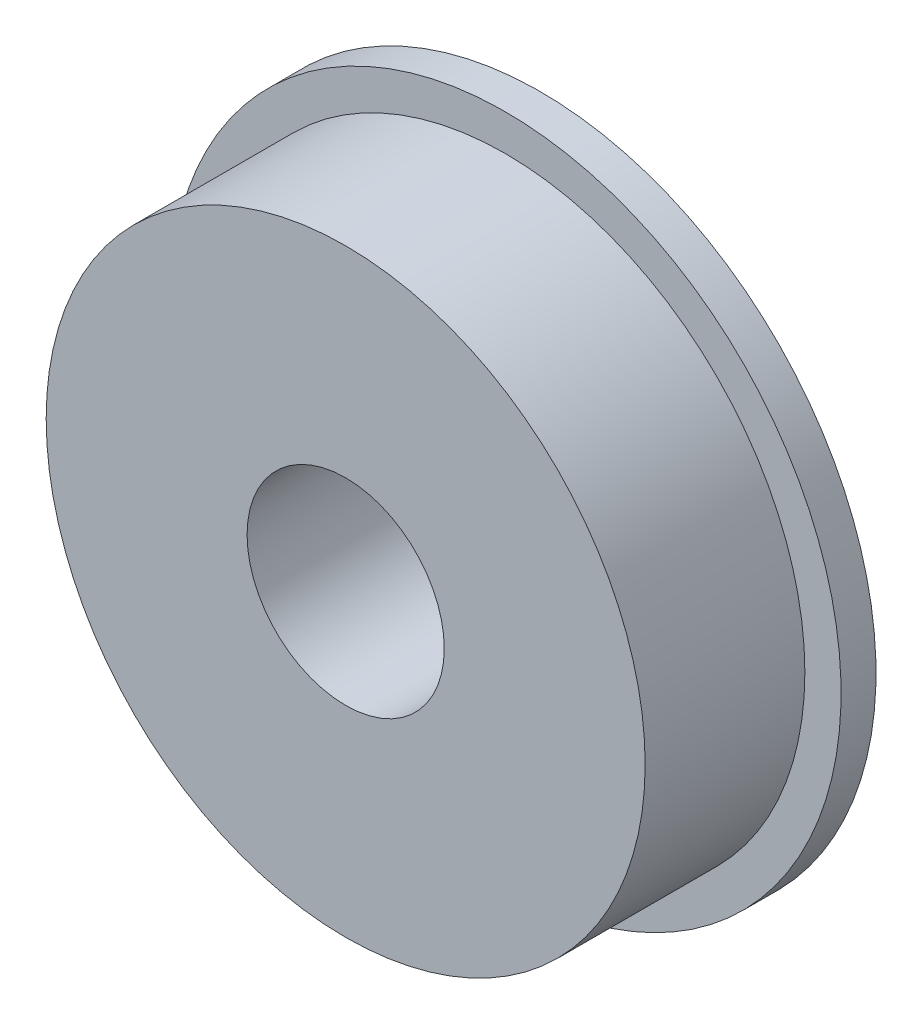
from build123d import *

# Parameters (mm, degrees)
SKETCH1_R           = 12
SKETCH1_R_2         = 3.95
BOSS_EXTRUDE1_DEPTH = 6.4
SKETCH2_R           = 13.45
SKETCH2_R_2         = 3.95
BOSS_EXTRUDE2_DEPTH = 1.4


with BuildPart() as part:
    # Sketch1 → Boss-Extrude1 (new body)
    with BuildSketch(Plane.XY):
        Circle(SKETCH1_R)
        Circle(SKETCH1_R_2, mode=Mode.SUBTRACT)
    extrude(amount=BOSS_EXTRUDE1_DEPTH)

    # Sketch2 → Boss-Extrude2 (add)
    with BuildSketch(Plane(origin=(0, 0, 0), x_dir=(-1, 0, 0), z_dir=(0, 0, -1))):
        Circle(SKETCH2_R)
        Circle(SKETCH2_R_2, mode=Mode.SUBTRACT)
    extrude(amount=BOSS_EXTRUDE2_DEPTH)


solid = part.part
